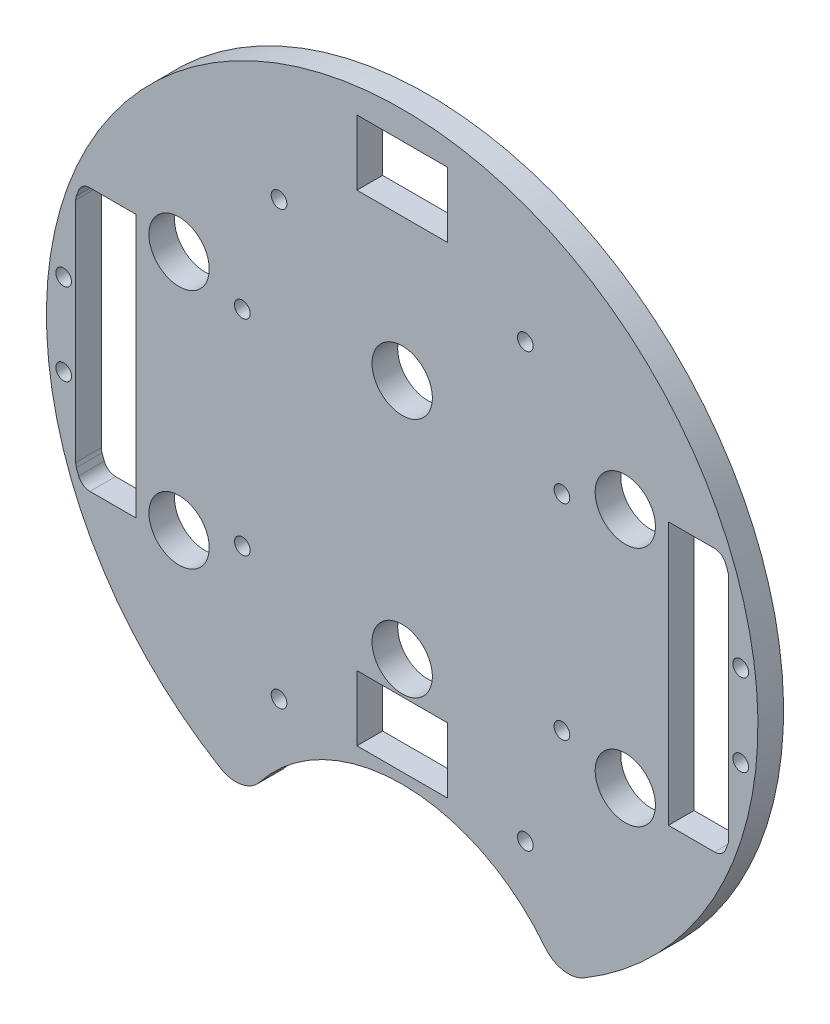
from build123d import *

# Parameters (mm, degrees)
BOSS_EXTRUDE2_DEPTH      = 5.3975
SKETCH2_W                = 19.05
SKETCH2_H                = 13.716
CUT_EXTRUDE1_DEPTH       = 107.104395791
SKETCH3_R                = 38.1
CUT_EXTRUDE2_DEPTH       = 107.104395791
FILLET1_R                = 6.35
SKETCH8_R                = 1.651
CUT_EXTRUDE7_DEPTH       = 75.692
SKETCH10_R               = 1.651
CUT_EXTRUDE9_DEPTH       = 97.79
SKETCH11_R               = 1.651
CUT_EXTRUDE10_DEPTH      = 150.876
SKETCH12_R               = 3.175
CUT_EXTRUDE11_DEPTH      = 103.378
CUT_EXTRUDE11_DEPTH_BACK = 48.768
SKETCH13_R               = 6.35
CUT_EXTRUDE12_DEPTH      = 26.416
SKETCH14_W               = 19.05
SKETCH14_H               = 13.716
CUT_EXTRUDE13_DEPTH      = 107.104395938
CUT_EXTRUDE14_DEPTH      = 107.104395938
FILLET2_R                = 2.54
FILLET3_R                = 2.54


with BuildPart() as part:
    # Sketch1 → Boss-Extrude2 (new body)
    with BuildSketch(Plane.XY):
        with BuildLine():
            ThreePointArc((-69.525975721, 27.94), (-74.93, 0), (-69.525975721, -27.94))
            ThreePointArc((-69.525975721, -27.94), (0, -74.93), (69.525975721, -27.94))
            ThreePointArc((69.525975721, -27.94), (73.56658977, -14.228906128), (74.93, 0))
            ThreePointArc((74.93, 0), (73.56658977, 14.228906128), (69.525975721, 27.94))
            ThreePointArc((69.525975721, 27.94), (0, 74.93), (-69.525975721, 27.94))
        make_face()
        Polygon((-67.493975721, 27.686), (-66.223975721, 27.686), (-56.063975721, 27.686), (-56.063975721, -27.686), (-66.223975721, -27.686), (-67.493975721, -27.686), (-67.493975721, -26.416), (-67.493975721, 26.416), align=None, mode=Mode.SUBTRACT)
        Polygon((67.493975721, 27.686), (67.493975721, 26.416), (67.493975721, -26.416), (67.493975721, -27.686), (66.223975721, -27.686), (56.063975721, -27.686), (56.063975721, 27.686), (66.223975721, 27.686), align=None, mode=Mode.SUBTRACT)
    extrude(amount=BOSS_EXTRUDE2_DEPTH)

    # Sketch2 → Cut-Extrude1 (cut, through all)
    with BuildSketch(Plane.XY.offset(5.3975)):
        with Locations((0, 62.23)):
            Rectangle(SKETCH2_W, SKETCH2_H)
    extrude(amount=-CUT_EXTRUDE1_DEPTH, mode=Mode.SUBTRACT)

    # Sketch3 → Cut-Extrude2 (cut, through all)
    with BuildSketch(Plane.XY.offset(5.3975)):
        with Locations((0, -86.312058398)):
            Circle(SKETCH3_R)
    extrude(amount=-CUT_EXTRUDE2_DEPTH, mode=Mode.SUBTRACT)

    # Fillet1
    fillet1_edges = [part.edges().sort_by_distance(p)[0] for p in [
        (-33.000960548, -67.271401821, 2.69875),
        (33.000960548, -67.271401821, 2.69875),
    ]]
    fillet(fillet1_edges, radius=FILLET1_R)

    # Sketch8 → Cut-Extrude7 (cut)
    with BuildSketch(Plane(origin=(30.092005081, 4.08352975, -11.4935), x_dir=(-1, 0, 0), z_dir=(0, 0, -1))):
        with Locations(Location((63.757223581, 17.50647025, 0), (0, 0, 180))):
            Circle(SKETCH8_R)
        with Locations(Location((63.757223581, -25.67352975, 0), (0, 0, 180))):
            Circle(SKETCH8_R)
        with Locations(Location((-3.552776419, -25.67352975, 0), (0, 0, 180))):
            Circle(SKETCH8_R)
        with Locations(Location((-3.552776419, 17.50647025, 0), (0, 0, 180))):
            Circle(SKETCH8_R)
    extrude(amount=-CUT_EXTRUDE7_DEPTH, mode=Mode.SUBTRACT)

    # Sketch10 → Cut-Extrude9 (cut)
    with BuildSketch(Plane(origin=(30.092005081, 4.08352975, -41.529), x_dir=(-1, 0, 0), z_dir=(0, 0, -1))):
        with Locations(Location((4.154396091, -49.728759131, 0), (0, 0, 180))):
            Circle(SKETCH10_R)
        with Locations(Location((56.02961407, -49.728759131, 0), (0, 0, 180))):
            Circle(SKETCH10_R)
        with Locations(Location((4.154396091, 41.38247025, 0), (0, 0, 180))):
            Circle(SKETCH10_R)
        with Locations(Location((56.02961407, 41.38247025, 0), (0, 0, 180))):
            Circle(SKETCH10_R)
    extrude(amount=-CUT_EXTRUDE9_DEPTH, mode=Mode.SUBTRACT)

    # Sketch11 → Cut-Extrude10 (cut)
    with BuildSketch(Plane(origin=(30.092005081, 4.08352975, 5.3975), x_dir=(1, 0, 0), z_dir=(0, 0, 1))):
        with Locations((-101.395980802, -12.71952975)):
            Circle(SKETCH11_R)
        with Locations((-101.395980802, 4.55247025)):
            Circle(SKETCH11_R)
        with Locations((41.211970641, -12.71952975)):
            Circle(SKETCH11_R)
        with Locations((41.211970641, 4.55247025)):
            Circle(SKETCH11_R)
    extrude(amount=-CUT_EXTRUDE10_DEPTH, mode=Mode.SUBTRACT)

    # Sketch12 → Cut-Extrude11 (cut, two sides)
    with BuildSketch(Plane(origin=(30.092005081, 4.08352975, -5.3975), x_dir=(-1, 0, 0), z_dir=(0, 0, -1))) as cut_extrude11_sk:
        with Locations(Location((-16.897994919, 21.31647025, 0), (0, 0, 180))):
            Circle(SKETCH12_R)
        with Locations(Location((77.082005081, 21.31647025, 0), (0, 0, 180))):
            Circle(SKETCH12_R)
        with Locations(Location((30.092005081, 21.31647025, 0), (0, 0, 180))):
            Circle(SKETCH12_R)
        with Locations(Location((77.082005081, -29.48352975, 0), (0, 0, 180))):
            Circle(SKETCH12_R)
        with Locations(Location((30.092005081, -29.48352975, 0), (0, 0, 180))):
            Circle(SKETCH12_R)
        with Locations(Location((-16.897994919, -29.48352975, 0), (0, 0, 180))):
            Circle(SKETCH12_R)
    extrude(amount=CUT_EXTRUDE11_DEPTH, mode=Mode.SUBTRACT)
    extrude(cut_extrude11_sk.sketch, amount=-CUT_EXTRUDE11_DEPTH_BACK, mode=Mode.SUBTRACT)

    # Sketch13 → Cut-Extrude12 (cut)
    with BuildSketch(Plane(origin=(0, 0, 0), x_dir=(-1, 0, 0), z_dir=(0, 0, -1))):
        with Locations((46.99, 25.4)):
            Circle(SKETCH13_R)
        with Locations((0, 25.4)):
            Circle(SKETCH13_R)
        with Locations((-46.99, 25.4)):
            Circle(SKETCH13_R)
        with Locations((-46.99, -25.4)):
            Circle(SKETCH13_R)
        with Locations((0, -25.4)):
            Circle(SKETCH13_R)
        with Locations((46.99, -25.4)):
            Circle(SKETCH13_R)
    extrude(amount=-CUT_EXTRUDE12_DEPTH, mode=Mode.SUBTRACT)

    # Sketch14 → Cut-Extrude13 (cut, through all)
    with BuildSketch(Plane.XY.offset(5.3975)):
        with Locations((0, -39.116)):
            Rectangle(SKETCH14_W, SKETCH14_H)
    extrude(amount=-CUT_EXTRUDE13_DEPTH, mode=Mode.SUBTRACT)

    # Sketch15 → Cut-Extrude14 (cut, through all)
    with BuildSketch(Plane(origin=(0, 0, 0), x_dir=(-1, 0, 0), z_dir=(0, 0, -1))):
        with BuildLine():
            ThreePointArc((67.493975721, -27.686), (68.149254897, -26.031335187), (68.763975721, -24.361178085))
            Line((68.763975721, -24.361178085), (68.763975721, 24.361178085))
            ThreePointArc((68.763975721, 24.361178085), (68.149254897, 26.031335187), (67.493975721, 27.686))
            Line((67.493975721, 27.686), (67.493975721, -27.686))
        make_face()
        with BuildLine():
            ThreePointArc((-68.763975721, -24.361178085), (-68.149254897, -26.031335187), (-67.493975721, -27.686))
            Line((-67.493975721, -27.686), (-67.493975721, 27.686))
            ThreePointArc((-67.493975721, 27.686), (-68.149254897, 26.031335187), (-68.763975721, 24.361178085))
            Line((-68.763975721, 24.361178085), (-68.763975721, -24.361178085))
        make_face()
    extrude(amount=-CUT_EXTRUDE14_DEPTH, mode=Mode.SUBTRACT)

    # Fillet2
    fillet2_edges = [part.edges().sort_by_distance(p)[0] for p in [
        (-67.493975721, 27.686, 2.69875),
        (-67.493975721, -27.686, 2.69875),
        (-68.763975721, 24.361178085, 2.69875),
        (-68.763975721, -24.361178085, 2.69875),
    ]]
    fillet(fillet2_edges, radius=FILLET2_R)

    # Fillet3
    fillet3_edges = [part.edges().sort_by_distance(p)[0] for p in [
        (67.493975721, -27.686, 2.69875),
        (67.493975721, 27.686, 2.69875),
        (68.763975721, -24.361178085, 2.69875),
        (68.763975721, 24.361178085, 2.69875),
    ]]
    fillet(fillet3_edges, radius=FILLET3_R)


solid = part.part
